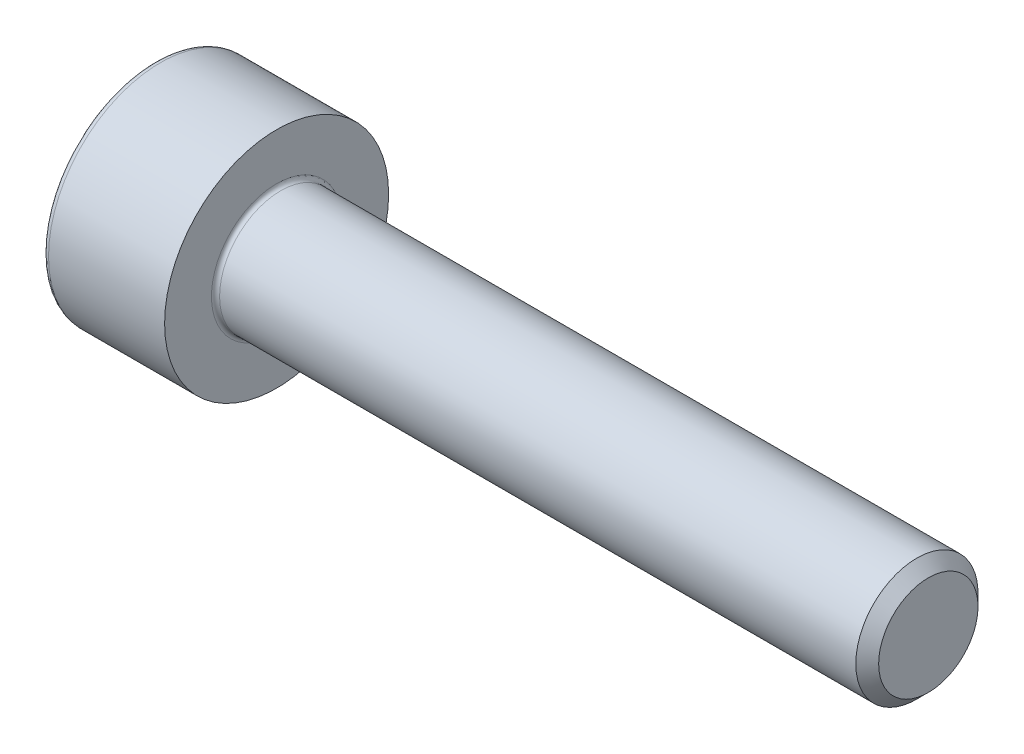
from build123d import *

# Parameters (mm, degrees)
FILLET1_R   = 0.1
FILLET2_R   = 0.15
HEX_2_DEPTH = 1.3


with BuildPart() as part:
    # BodySke → Base-Revolve (revolve)
    with BuildSketch(Plane.XY):
        Polygon((0, 0), (0, 2.75), (3, 2.75), (3, 1.5), (18.7195, 1.5), (19, 1.2195), (19, 0), align=None)
    revolve(axis=Axis((-31.75, 0, 0), (1, 0, 0)))

    # Fillet1
    fillet1_edges = [part.edges().sort_by_distance(p)[0] for p in [
        (3, -1.5, 0),
    ]]
    fillet(fillet1_edges, radius=FILLET1_R)

    # Fillet2
    fillet2_edges = [part.edges().sort_by_distance(p)[0] for p in [
        (0, -2.75, 0),
    ]]
    fillet(fillet2_edges, radius=FILLET2_R)

    # Sketch2 → Hex-PreBroach (revolve, cut)
    with BuildSketch(Plane.XY):
        Polygon((0, 1.28), (1.3, 1.28), (2.039008345, 0), (0, 0), align=None)
    revolve(axis=Axis((0, 0, 0), (1, 0, 0)), mode=Mode.SUBTRACT)

    # Sketch3 → Hex 2 (cut)
    with BuildSketch(Plane(origin=(0, 0, 0), x_dir=(0, 0.5, 0.866025404), z_dir=(-1, 0, 0))):
        Polygon((0.739008345, 1.28), (-0.739008345, 1.28), (-1.478016689, 0), (-0.739008345, -1.28), (0.739008345, -1.28), (1.478016689, 0), align=None)
    extrude(amount=-HEX_2_DEPTH, mode=Mode.SUBTRACT)


solid = part.part
